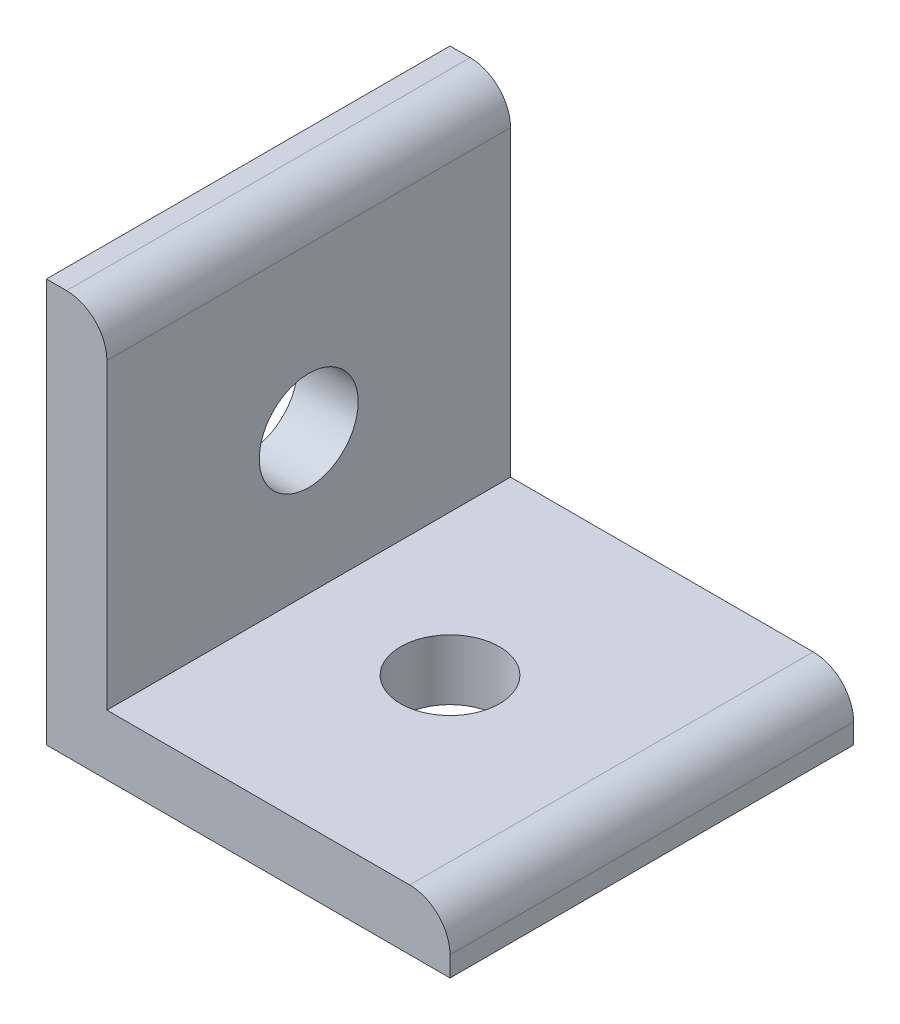
from build123d import *

# Parameters (mm, degrees)
EXTRUDE_1_DEPTH     = 20
SKETCH_3_R          = 2.45
CUT_EXTRUDE_1_DEPTH = 2.999162
SKETCH_5_R          = 2.45
CUT_EXTRUDE_2_DEPTH = 2.994438
FILLET_1_R          = 2
FILLET_2_R          = 2


with BuildPart() as part:
    # 草图1 → 凸台-拉伸1 (new body)
    with BuildSketch(Plane.XY):
        Polygon((0, 0), (20.001593334, 0), (20.001593334, 2.994438252), (2.999161685, 2.994438252), (2.999161685, 19.996869901), (0, 19.996869901), align=None)
    extrude(amount=EXTRUDE_1_DEPTH)

    # 草图3 → 切除-拉伸1 (cut)
    with BuildSketch(Plane(origin=(2.999161685, 0, 0), x_dir=(0, 0, -1), z_dir=(1, 0, 0))):
        with Locations((-10, 9.996869901)):
            Circle(SKETCH_3_R)
    extrude(amount=-CUT_EXTRUDE_1_DEPTH, mode=Mode.SUBTRACT)

    # 草图5 → 切除-拉伸2 (cut)
    with BuildSketch(Plane(origin=(0, 2.994438252, 0), x_dir=(1, 0, 0), z_dir=(0, 1, 0))):
        with Locations((10.001593334, -10)):
            Circle(SKETCH_5_R)
    extrude(amount=-CUT_EXTRUDE_2_DEPTH, mode=Mode.SUBTRACT)

    # 圆角1
    fillet_1_edges = [part.edges().sort_by_distance(p)[0] for p in [
        (2.999161685, 19.996869901, 10),
    ]]
    fillet(fillet_1_edges, radius=FILLET_1_R)

    # 圆角2
    fillet_2_edges = [part.edges().sort_by_distance(p)[0] for p in [
        (20.001593334, 2.994438252, 10),
    ]]
    fillet(fillet_2_edges, radius=FILLET_2_R)


solid = part.part
